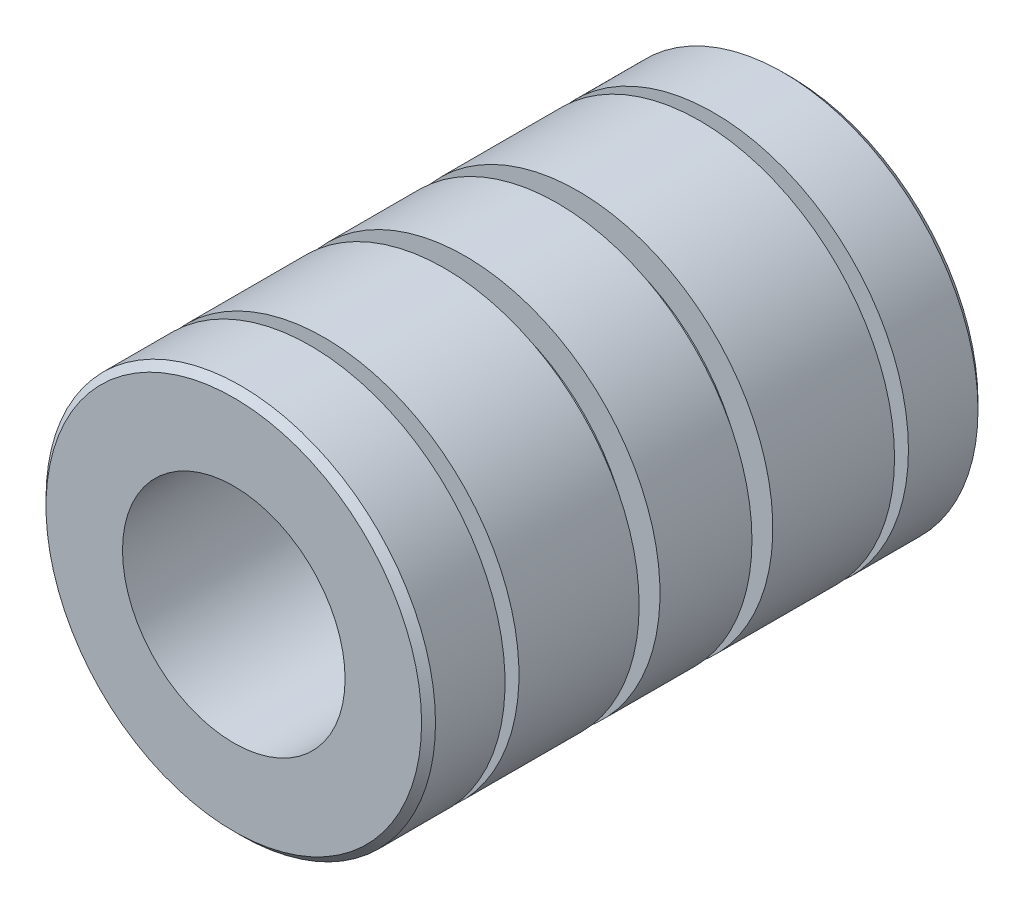
from build123d import *

# Parameters (mm, degrees)
SKETCH2_R           = 11.1125
BOSS_EXTRUDE1_DEPTH = 31.75
SKETCH3_R           = 6.35
CUT_EXTRUDE1_DEPTH  = 32.75
SKETCH4_W           = 3.175
SKETCH4_H           = 0.79375
CHAMFER1_SIZE       = 0.396875
SKETCH5_W           = 3.175
SKETCH5_H           = 1.190625


with BuildPart() as part:
    # Sketch2 → Boss-Extrude1 (new body)
    with BuildSketch(Plane.XY):
        Circle(SKETCH2_R)
    extrude(amount=BOSS_EXTRUDE1_DEPTH)

    # Sketch3 → Cut-Extrude1 (cut, through all)
    with BuildSketch(Plane.XY.offset(31.75)):
        Circle(SKETCH3_R)
    extrude(amount=-CUT_EXTRUDE1_DEPTH, mode=Mode.SUBTRACT)

    # Sketch4 → Cut-Revolve1 (revolve, cut)
    with BuildSketch(Plane(origin=(0, 0, 0), x_dir=(1, 0, 0), z_dir=(0, 1, 0))):
        with Locations((11.1125, -26.9875)):
            Rectangle(SKETCH4_W, SKETCH4_H)
        with Locations((11.1125, -4.7625)):
            Rectangle(SKETCH4_W, SKETCH4_H)
    revolve(axis=Axis((0, 0, 31.75), (0, 0, -1)), mode=Mode.SUBTRACT)

    # Chamfer1
    chamfer1_edges = [part.edges().sort_by_distance(p)[0] for p in [
        (-11.1125, 0, 0),
        (-11.1125, 0, 31.75),
    ]]
    chamfer(chamfer1_edges, length=CHAMFER1_SIZE)

    # Sketch5 → Cut-Revolve2 (revolve, cut)
    with BuildSketch(Plane(origin=(0, 0, 0), x_dir=(1, 0, 0), z_dir=(0, 1, 0))):
        with Locations((11.1125, -12.7)):
            Rectangle(SKETCH5_W, SKETCH5_H)
        with Locations((11.1125, -19.137777624)):
            Rectangle(SKETCH5_W, SKETCH5_H)
    revolve(axis=Axis((0, 0, 31.75), (0, 0, -1)), mode=Mode.SUBTRACT)


solid = part.part
